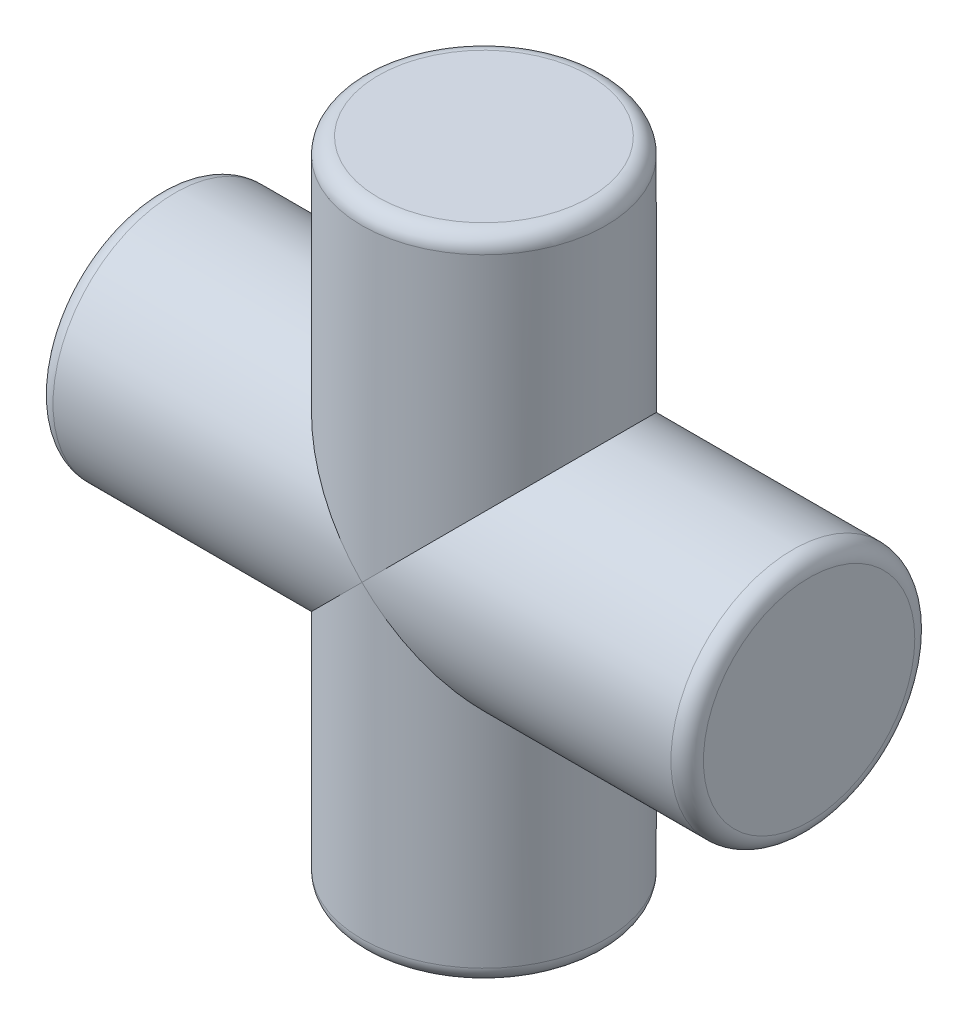
from build123d import *

# Parameters (mm, degrees)
SKETCH1_R           = 7.5
BOSS_EXTRUDE1_DEPTH = 20
SKETCH2_R           = 7.5
BOSS_EXTRUDE2_DEPTH = 20
FILLET1_R           = 1


with BuildPart() as part:
    # Sketch1 → Boss-Extrude1 (new body, symmetric)
    with BuildSketch(Plane(origin=(0, 0, 0), x_dir=(1, 0, 0), z_dir=(0, 1, 0))):
        Circle(SKETCH1_R)
    extrude(amount=BOSS_EXTRUDE1_DEPTH, both=True)

    # Sketch2 → Boss-Extrude2 (add, symmetric)
    with BuildSketch(Plane(origin=(0, 0, 0), x_dir=(0, 0, -1), z_dir=(1, 0, 0))):
        Circle(SKETCH2_R)
    extrude(amount=BOSS_EXTRUDE2_DEPTH, both=True)

    # Fillet1
    fillet1_edges = [part.edges().sort_by_distance(p)[0] for p in [
        (-7.5, -20, 0),
        (-7.5, 20, 0),
        (-20, 0, 7.5),
        (20, 0, 7.5),
    ]]
    fillet(fillet1_edges, radius=FILLET1_R)


solid = part.part
